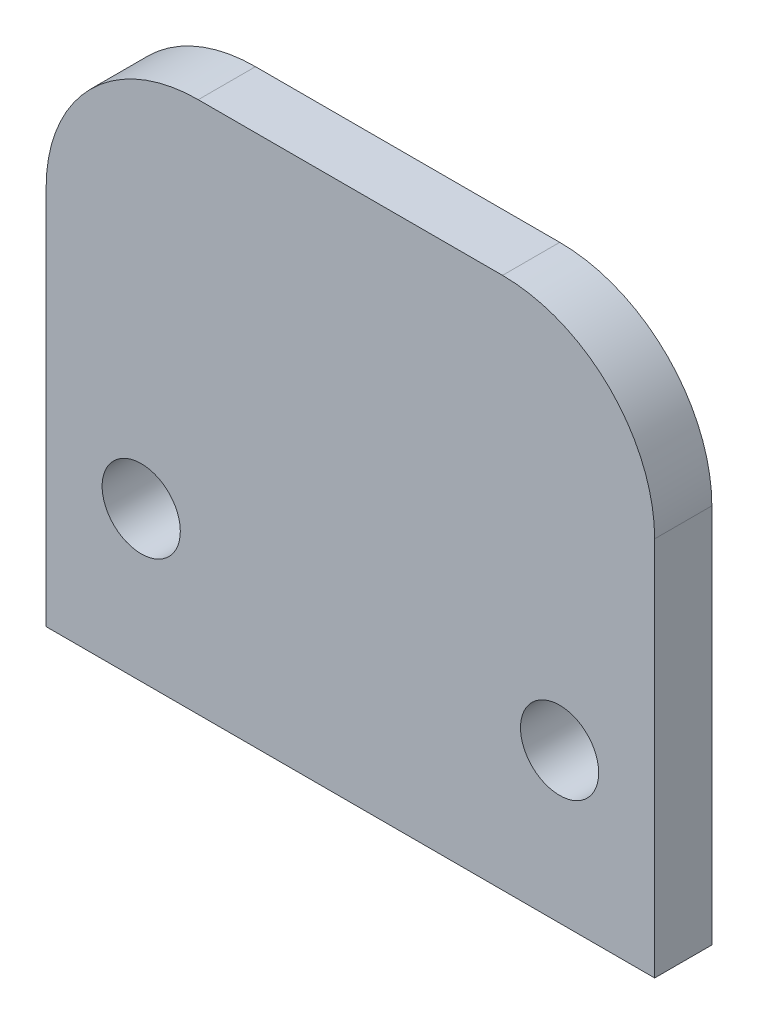
from build123d import *

# Parameters (mm, degrees)
SKETCH1_W                = 50.8
SKETCH1_H                = 44.45
BOSS_EXTRUDE1_DEPTH      = 2.3876
F_0_257_DIAMETER_HOLE1_D = 6.5278
FILLET1_R                = 12.7


with BuildPart() as part:
    # Sketch1 → Boss-Extrude1 (new body, symmetric)
    with BuildSketch(Plane.XY):
        with Locations((0, 22.225)):
            Rectangle(SKETCH1_W, SKETCH1_H)
    extrude(amount=BOSS_EXTRUDE1_DEPTH, both=True)

    # F (0.257) Diameter Hole1 (through all)
    with Locations(Plane.XY.offset(2.3876)):
        with Locations((-17.4625, 12.4968), (17.4625, 12.4968)):
            Hole(F_0_257_DIAMETER_HOLE1_D / 2)

    # Fillet1
    fillet1_edges = [part.edges().sort_by_distance(p)[0] for p in [
        (-25.4, 44.45, 0),
        (25.4, 44.45, 0),
    ]]
    fillet(fillet1_edges, radius=FILLET1_R)


solid = part.part
